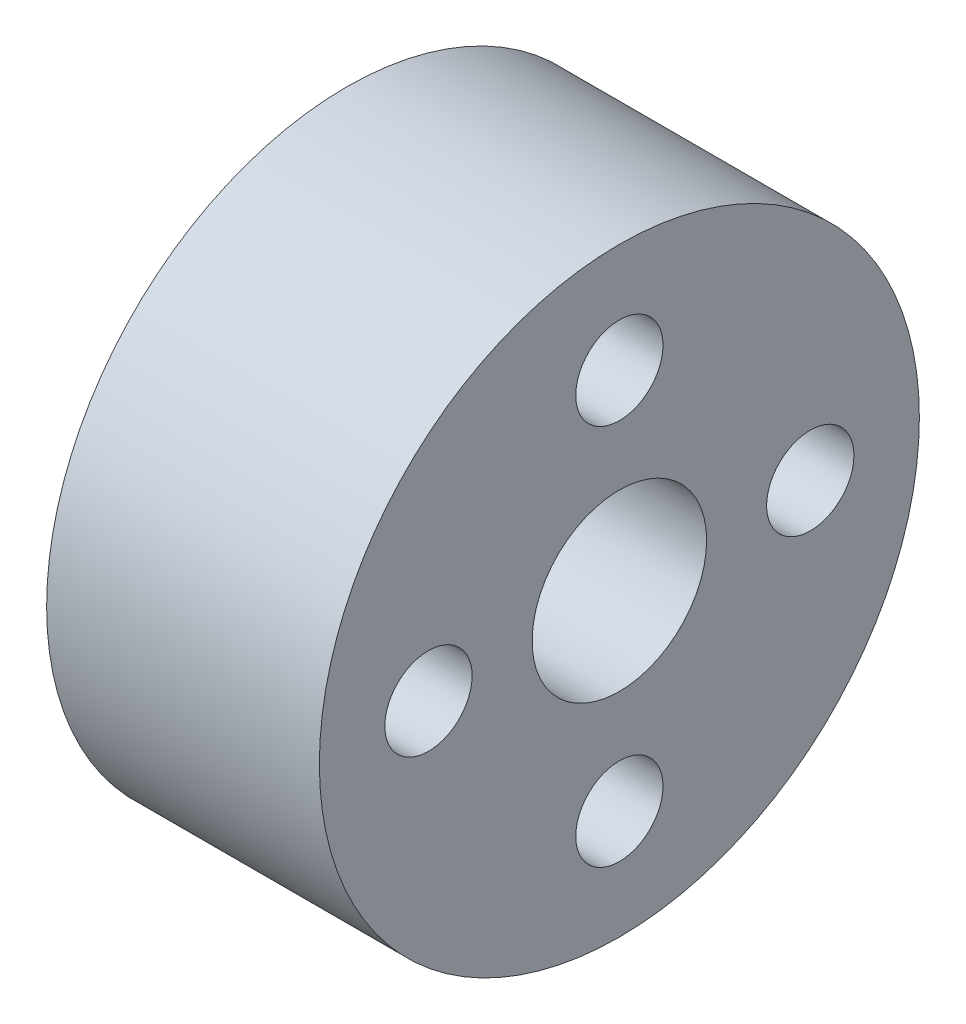
from build123d import *

# Parameters (mm, degrees)
SKETCH1_R           = 11
SKETCH1_R_2         = 1.6
SKETCH1_R_3         = 3.2
BOSS_EXTRUDE1_DEPTH = 10


with BuildPart() as part:
    # Sketch1 → Boss-Extrude1 (new body)
    with BuildSketch(Plane(origin=(0, 0, 0), x_dir=(0, 0, -1), z_dir=(1, 0, 0))):
        Circle(SKETCH1_R)
        with Locations((0, 7)):
            Circle(SKETCH1_R_2, mode=Mode.SUBTRACT)
        with Locations((-7, 0)):
            Circle(SKETCH1_R_2, mode=Mode.SUBTRACT)
        with Locations((0, -7)):
            Circle(SKETCH1_R_2, mode=Mode.SUBTRACT)
        with Locations((7, 0)):
            Circle(SKETCH1_R_2, mode=Mode.SUBTRACT)
        Circle(SKETCH1_R_3, mode=Mode.SUBTRACT)
    extrude(amount=BOSS_EXTRUDE1_DEPTH)


solid = part.part
